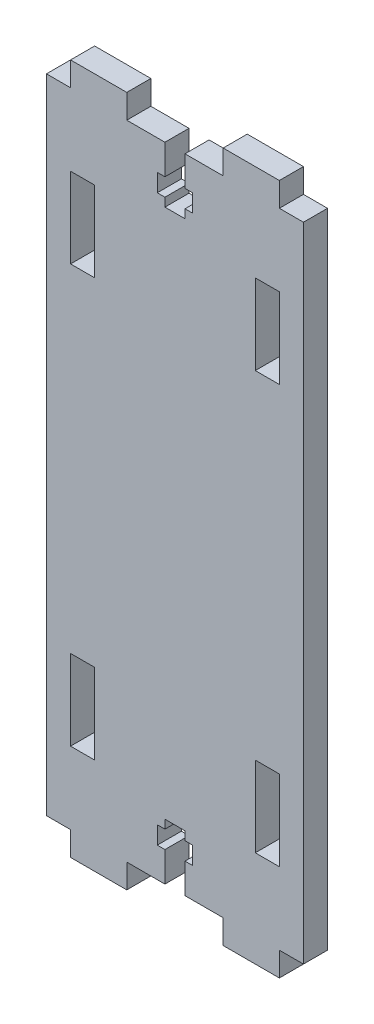
from build123d import *

# Parameters (mm, degrees)
SKETCH_1_W          = 32
SKETCH_1_H          = 86
EXTRUDE_1_DEPTH     = 3
SKETCH_2_W          = 12
SKETCH_2_H          = 3
SKETCH_2_W_2        = 3
CUT_EXTRUDE_1_DEPTH = 4
SKETCH_3_W          = 3
SKETCH_3_H          = 10
CUT_EXTRUDE_2_DEPTH = 4
CUT_EXTRUDE_3_DEPTH = 10


with BuildPart() as part:
    # 스케치1 → 보스-돌출1 (new body)
    with BuildSketch(Plane.XY):
        with Locations((16, 43)):
            Rectangle(SKETCH_1_W, SKETCH_1_H)
    extrude(amount=EXTRUDE_1_DEPTH)

    # 스케치2 → 컷-돌출1 (cut, through all)
    with BuildSketch(Plane.XY.offset(3)):
        with Locations((16, 84.5)):
            Rectangle(SKETCH_2_W, SKETCH_2_H)
        with Locations((1.5, 84.5)):
            Rectangle(SKETCH_2_W_2, SKETCH_2_H)
        with Locations((30.5, 84.5)):
            Rectangle(SKETCH_2_W_2, SKETCH_2_H)
        with Locations((16, 1.5)):
            Rectangle(SKETCH_2_W, SKETCH_2_H)
        with Locations((1.5, 1.5)):
            Rectangle(SKETCH_2_W_2, SKETCH_2_H)
        with Locations((30.5, 1.5)):
            Rectangle(SKETCH_2_W_2, SKETCH_2_H)
    extrude(amount=-CUT_EXTRUDE_1_DEPTH, mode=Mode.SUBTRACT)

    # 스케치3 → 컷-돌출2 (cut, through all)
    with BuildSketch(Plane.XY.offset(3)):
        with Locations((27.5, 69)):
            Rectangle(SKETCH_3_W, SKETCH_3_H)
        with Locations((4.5, 69)):
            Rectangle(SKETCH_3_W, SKETCH_3_H)
        with Locations((27.5, 17)):
            Rectangle(SKETCH_3_W, SKETCH_3_H)
        with Locations((4.5, 17)):
            Rectangle(SKETCH_3_W, SKETCH_3_H)
    extrude(amount=-CUT_EXTRUDE_2_DEPTH, mode=Mode.SUBTRACT)

    # 스케치4 → 컷-돌출3 (cut)
    with BuildSketch(Plane.XY.offset(3)):
        Polygon((14.75, 3), (17.25, 3), (17.25, 6.727769783), (18.2, 6.727769783), (18.2, 8.927769783), (17.25, 8.927769783), (17.25, 10), (14.75, 10), (14.75, 8.927769783), (13.8, 8.927769783), (13.8, 6.727769783), (14.75, 6.727769783), align=None)
        Polygon((13.8, 77.072230217), (14.75, 77.072230217), (14.75, 76), (17.25, 76), (17.25, 77.072230217), (18.2, 77.072230217), (18.2, 79.272230217), (17.25, 79.272230217), (17.25, 83), (14.75, 83), (14.75, 79.272230217), (13.8, 79.272230217), align=None)
    extrude(amount=-CUT_EXTRUDE_3_DEPTH, mode=Mode.SUBTRACT)


solid = part.part
